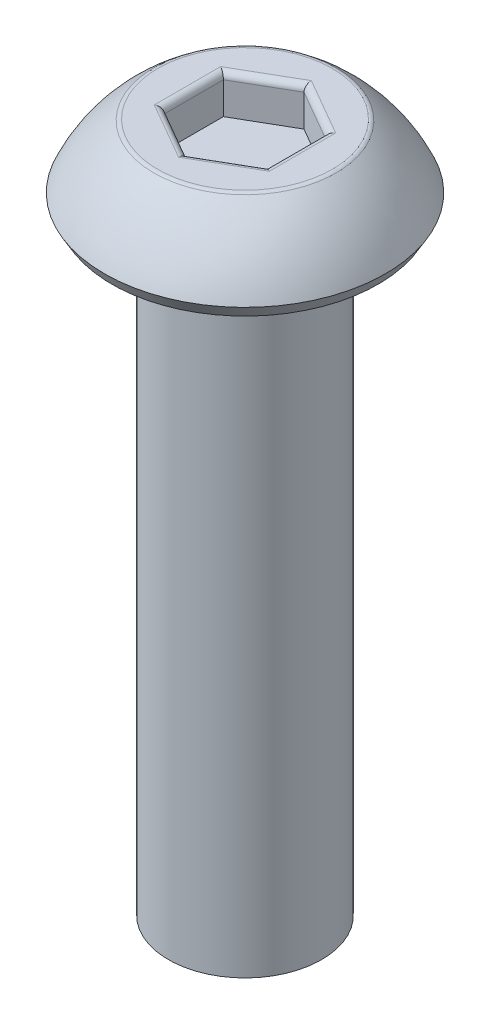
from build123d import *

# Parameters (mm, degrees)
CUT_EXTRUDE1_DEPTH = 0.75
FILLET1_R          = 0.125


with BuildPart() as part:
    # Sketch1 → Revolve1 (revolve)
    with BuildSketch(Plane(origin=(0, 0, 0), x_dir=(0, 0, -1), z_dir=(1, 0, 0))):
        with BuildLine():
            Line((0, 1.5), (-1.75, 1.5))
            ThreePointArc((-1.75, 1.5), (-2.334912942, 0.942930354), (-2.75, 0.25))
            Line((-2.75, 0.25), (-2.605662433, 0))
            Line((-2.605662433, 0), (-1.5, 0))
            Line((-1.5, 0), (-1.5, -12))
            Line((-1.5, -12), (0, -12))
            Line((0, -12), (0, 1.5))
        make_face()
    revolve(axis=Axis((0, -12, 0), (0, 1, 0)))

    # Sketch2 → Cut-Extrude1 (cut)
    with BuildSketch(Plane(origin=(0, 1.5, 0), x_dir=(1, 0, 0), z_dir=(0, 1, 0))):
        Polygon((0, 1.154700538), (-1, 0.577350269), (-1, -0.577350269), (0, -1.154700538), (1, -0.577350269), (1, 0.577350269), align=None)
    extrude(amount=-CUT_EXTRUDE1_DEPTH, mode=Mode.SUBTRACT)

    # Fillet1
    fillet1_edges = [part.edges().sort_by_distance(p)[0] for p in [
        (0.5, 1.5, -0.866025404),
        (-0.5, 1.5, -0.866025404),
        (-1, 1.5, 0),
        (-0.5, 1.5, 0.866025404),
        (0.5, 1.5, 0.866025404),
        (1, 1.5, 0),
        (0, 1.5, -1.75),
    ]]
    fillet(fillet1_edges, radius=FILLET1_R)


solid = part.part
